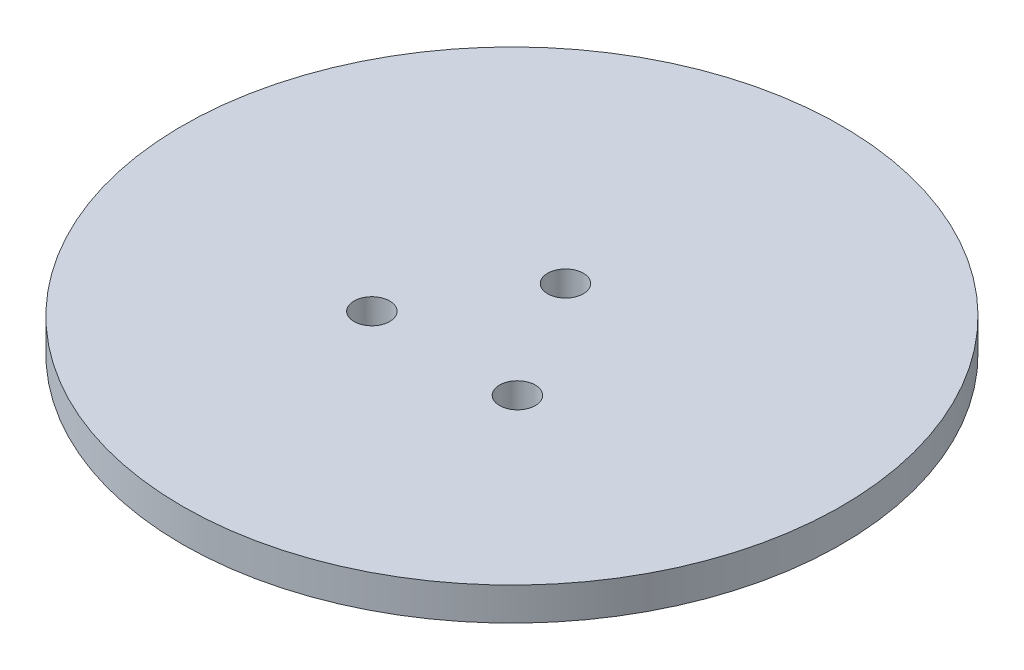
from build123d import *

# Parameters (mm, degrees)
SKETCH1_R             = 60.96
SKETCH1_R_2           = 3.302
EXTRUDE1_DEPTH        = 6.096
SKETCH2_R             = 3.302
BOSS_EXTRUDE1_DEPTH   = 25.4
BOSS_EXTRUDE1_2_DEPTH = 25.4
BOSS_EXTRUDE1_3_DEPTH = 25.4
SKETCH3_R             = 1.27
CUT_EXTRUDE1_DEPTH    = 32.496


with BuildPart() as part:
    # Sketch1 → Extrude1 (new body)
    with BuildSketch(Plane(origin=(0, 0, 0), x_dir=(1, 0, 0), z_dir=(0, 1, 0))):
        Circle(SKETCH1_R)
        with Locations((-0.254, 10.16)):
            Circle(SKETCH1_R_2, mode=Mode.SUBTRACT)
        with Locations((-13.716, -12.192)):
            Circle(SKETCH1_R_2, mode=Mode.SUBTRACT)
        with Locations((13.208, -12.192)):
            Circle(SKETCH1_R_2, mode=Mode.SUBTRACT)
    extrude(amount=EXTRUDE1_DEPTH)


with BuildPart() as body_2:
    # Sketch2 → Boss-Extrude1 (new body)
    with BuildSketch(Plane.XZ):
        with Locations((13.208, 12.192)):
            Circle(SKETCH2_R)
    extrude(amount=BOSS_EXTRUDE1_DEPTH)


with BuildPart() as body_3:
    # Sketch2 → Boss-Extrude1 2 (new body)
    with BuildSketch(Plane.XZ):
        with Locations((-0.254, -10.16)):
            Circle(SKETCH2_R)
    extrude(amount=BOSS_EXTRUDE1_2_DEPTH)


with BuildPart() as body_4:
    # Sketch2 → Boss-Extrude1 3 (new body)
    with BuildSketch(Plane.XZ):
        with Locations((-13.716, 12.192)):
            Circle(SKETCH2_R)
    extrude(amount=BOSS_EXTRUDE1_3_DEPTH)


with BuildPart() as cut_extrude1_tool:
    # Sketch3 → Cut-Extrude1 (new body, through all)
    with BuildSketch(Plane.XZ.offset(25.4)):
        with Locations((-0.254, -10.16)):
            Circle(SKETCH3_R)
        with Locations((13.208, 12.192)):
            Circle(SKETCH3_R)
        with Locations((-13.716, 12.192)):
            Circle(SKETCH3_R)
    extrude(amount=-CUT_EXTRUDE1_DEPTH)


with BuildPart() as body_2_1:
    add(body_2.part)

    # Cut-Extrude1: cut by cut_extrude1_tool
    add(cut_extrude1_tool.part, mode=Mode.SUBTRACT)


with BuildPart() as body_3_1:
    add(body_3.part)

    # Cut-Extrude1: cut by cut_extrude1_tool
    add(cut_extrude1_tool.part, mode=Mode.SUBTRACT)


with BuildPart() as body_4_1:
    add(body_4.part)

    # Cut-Extrude1: cut by cut_extrude1_tool
    add(cut_extrude1_tool.part, mode=Mode.SUBTRACT)


solid = Compound([part.part, body_2_1.part, body_3_1.part, body_4_1.part])
